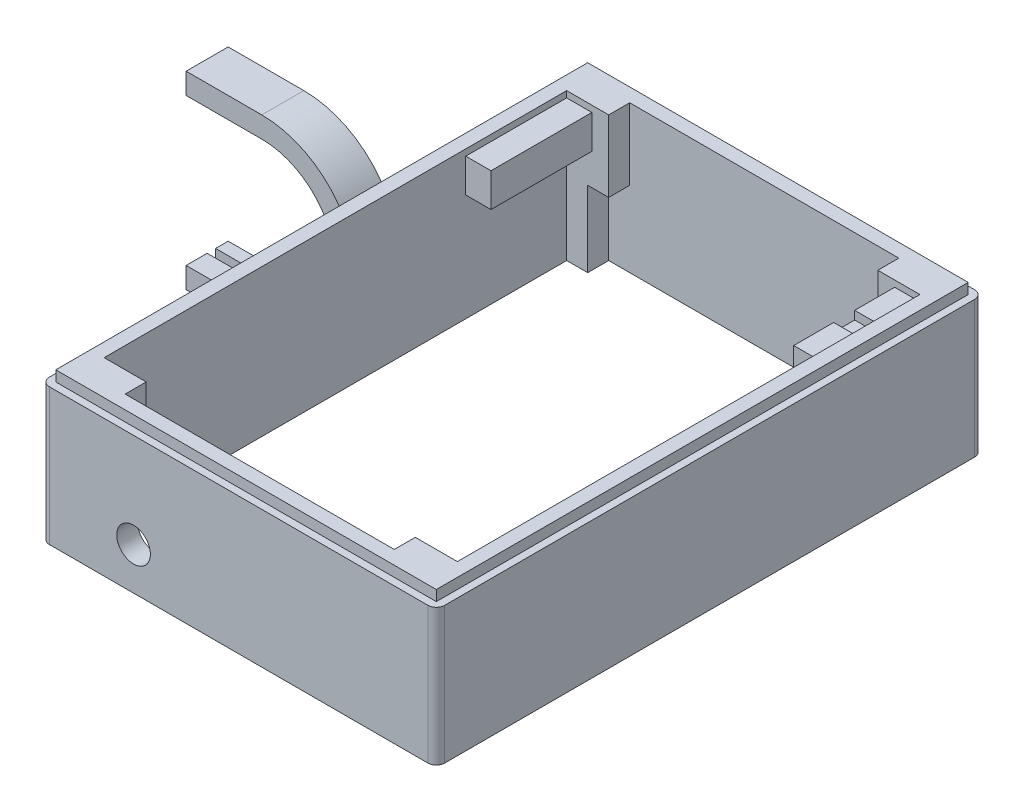
from build123d import *

# Parameters (mm, degrees)
SKETCH1_W            = 94
SKETCH1_H            = 130
BOSS_EXTRUDE1_DEPTH  = 35
SKETCH3_W            = 24
SKETCH3_H            = 8
BOSS_EXTRUDE2_DEPTH  = 6
SKETCH4_W            = 6
SKETCH4_H            = 5
CUT_EXTRUDE1_DEPTH   = 2
SKETCH5_W            = 5
SKETCH5_H            = 5
CUT_EXTRUDE2_DEPTH   = 18
LPATTERN1_COUNT      = 2
LPATTERN1_PITCH      = 69
LPATTERN1_COUNT_DIR2 = 2
LPATTERN1_PITCH_DIR2 = 115
FILLET1_R            = 2
SKETCH6_R            = 4
CUT_EXTRUDE3_DEPTH   = 7
SKETCH7_W            = 90.5
SKETCH7_H            = 126.5
CUT_EXTRUDE4_DEPTH   = 2.5
SKETCH14_W           = 8
SKETCH14_H           = 10
BOSS_EXTRUDE6_DEPTH  = 5
BOSS_EXTRUDE9_DEPTH  = 5
CUT_EXTRUDE6_DEPTH   = 2


with BuildPart() as part:
    # Sketch1 → Boss-Extrude1 (new body)
    with BuildSketch(Plane(origin=(0, 0, 0), x_dir=(1, 0, 0), z_dir=(0, 1, 0))):
        with Locations((47, 65)):
            Rectangle(SKETCH1_W, SKETCH1_H)
        Polygon((79, 125), (79, 120), (89, 120), (89, 10), (79, 10), (79, 5), (15, 5), (15, 10), (5, 10), (5, 120), (15, 120), (15, 125), align=None, mode=Mode.SUBTRACT)
    extrude(amount=BOSS_EXTRUDE1_DEPTH)

    # Sketch3 → Boss-Extrude2 (add)
    with BuildSketch(Plane(origin=(5, 0, 0), x_dir=(0, 0, -1), z_dir=(1, 0, 0))):
        with Locations((108, 29.5)):
            Rectangle(SKETCH3_W, SKETCH3_H)
    boss_extrude2 = extrude(amount=BOSS_EXTRUDE2_DEPTH)

    # Mirror3: Boss-Extrude2 across plane
    add(boss_extrude2.mirror(Plane.ZY.offset(-47)))

    # Sketch4 → Cut-Extrude1 (cut)
    with BuildSketch(Plane(origin=(0, 33.5, 0), x_dir=(1, 0, 0), z_dir=(0, 1, 0))):
        with Locations((86, 108)):
            Rectangle(SKETCH4_W, SKETCH4_H)
    extrude(amount=-CUT_EXTRUDE1_DEPTH, mode=Mode.SUBTRACT)

    # Sketch5 → Cut-Extrude2 (cut)
    with BuildSketch(Plane.XZ):
        with Locations((81.5, -122.5)):
            Rectangle(SKETCH5_W, SKETCH5_H)
    cut_extrude2 = extrude(amount=-CUT_EXTRUDE2_DEPTH, mode=Mode.SUBTRACT)

    # LPattern1: Cut-Extrude2 2 × 2
    with Locations(*[(-i * LPATTERN1_PITCH, 0, j * LPATTERN1_PITCH_DIR2) for i in range(LPATTERN1_COUNT) for j in range(LPATTERN1_COUNT_DIR2) if (i, j) != (0, 0)]):
        add(cut_extrude2, mode=Mode.SUBTRACT)

    # Fillet1
    fillet1_edges = [part.edges().sort_by_distance(p)[0] for p in [
        (0, 17.5, 0),
        (94, 17.5, 0),
        (94, 17.5, -130),
        (0, 17.5, -130),
    ]]
    fillet(fillet1_edges, radius=FILLET1_R)

    # Sketch6 → Cut-Extrude3 (cut)
    with BuildSketch(Plane.XY):
        with Locations((22, 10)):
            Circle(SKETCH6_R)
    extrude(amount=-CUT_EXTRUDE3_DEPTH, mode=Mode.SUBTRACT)

    # Sketch7 → Cut-Extrude4 (cut)
    with BuildSketch(Plane(origin=(0, 35, 0), x_dir=(1, 0, 0), z_dir=(0, 1, 0))):
        with BuildLine():
            Line((94, 2), (94, 128))
            ThreePointArc((94, 128), (93.414213562, 129.414213562), (92, 130))
            Line((92, 130), (2, 130))
            ThreePointArc((2, 130), (0.585786438, 129.414213562), (0, 128))
            Line((0, 128), (0, 2))
            ThreePointArc((0, 2), (0.585786438, 0.585786438), (2, 0))
            Line((2, 0), (92, 0))
            ThreePointArc((92, 0), (93.414213562, 0.585786438), (94, 2))
        make_face()
        with Locations((47, 65)):
            Rectangle(SKETCH7_W, SKETCH7_H, mode=Mode.SUBTRACT)
    extrude(amount=-CUT_EXTRUDE4_DEPTH, mode=Mode.SUBTRACT)

    # Sketch14 → Boss-Extrude6 (add)
    with BuildSketch(Plane.ZY):
        with Locations((-80, 16.25)):
            Rectangle(SKETCH14_W, SKETCH14_H)
    extrude(amount=BOSS_EXTRUDE6_DEPTH)


with BuildPart() as body_2:
    # Sketch17 → Boss-Extrude9 (new, symmetric)
    with BuildSketch(Plane.XY.offset(-80)):
        with BuildLine():
            Line((-22.5, 38.75), (-40.5, 38.75))
            Line((-40.5, 38.75), (-40.5, 33.75))
            Line((-40.5, 33.75), (-22.5, 33.75))
            ThreePointArc((-22.5, 33.75), (-5, 16.25), (-22.5, -1.25))
            Line((-22.5, -1.25), (-40.5, -1.25))
            Line((-40.5, -1.25), (-40.5, -6.25))
            Line((-40.5, -6.25), (-22.5, -6.25))
            ThreePointArc((-22.5, -6.25), (0, 16.25), (-22.5, 38.75))
        make_face()
    extrude(amount=BOSS_EXTRUDE9_DEPTH, both=True)

    # Sketch18 → Cut-Extrude6 (cut)
    with BuildSketch(Plane.XZ.offset(-33.75)):
        Polygon((-22.5, -82), (-40.5, -82), (-40.5, -80), (-24.5, -80), (-24.5, -78), (-22.5, -78), align=None)
    cut_extrude6 = extrude(amount=-CUT_EXTRUDE6_DEPTH, mode=Mode.SUBTRACT)

    # Mirror4: Cut-Extrude6 across plane
    add(cut_extrude6.mirror(Plane(origin=(0, 16.25, 0), x_dir=(0, 0, 1), z_dir=(0, -1, 0))), mode=Mode.SUBTRACT)


solid = Compound([part.part, body_2.part])
